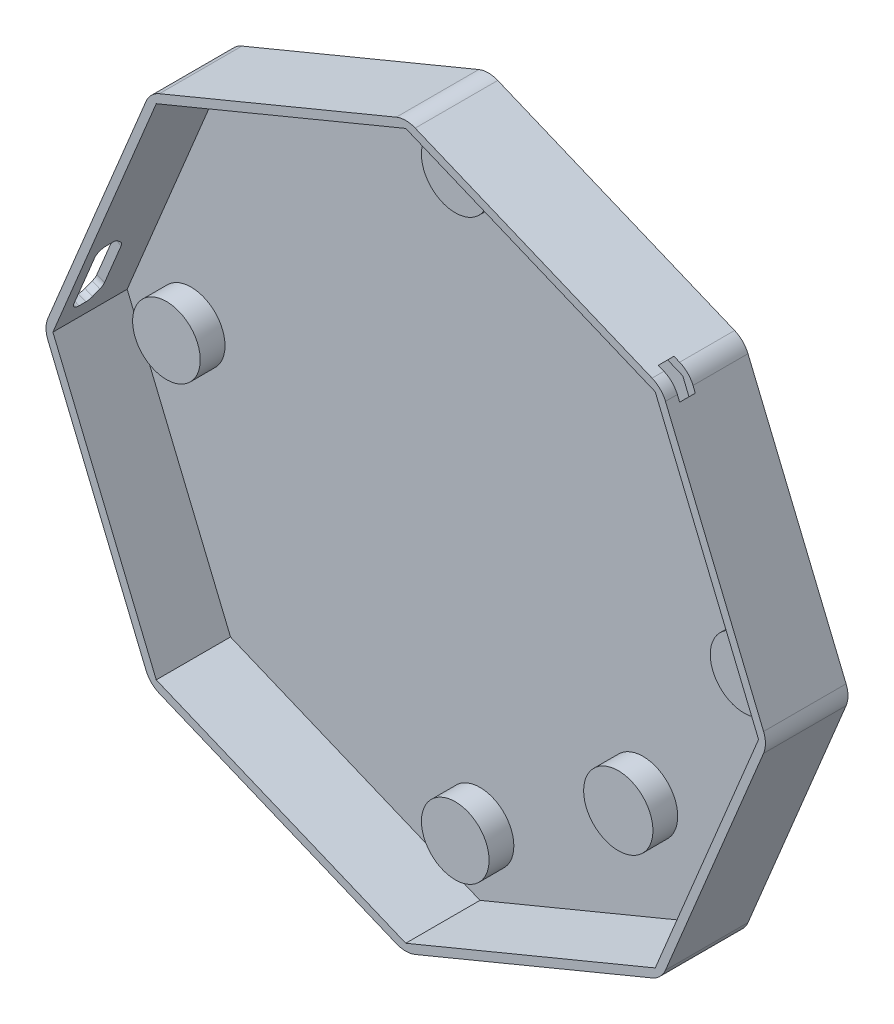
from build123d import *

# Parameters (mm, degrees)
BOSS_EXTRU_1_DEPTH           = 10
ESQUISSE2_R                  = 3.1
ENL_V_MAT_EXTRU_1_DEPTH      = 3
COQUE2_T                     = -1
CONG_1_R                     = 3
ENL_V_MAT_EXTRU_2_DEPTH      = 10
ESQUISSE4_R                  = 4.199805961
BOSS_EXTRU_2_DEPTH           = 3
ESQUISSE5_W                  = 3.651716426
ESQUISSE5_H                  = 1.9
ENL_V_MAT_EXTRU_3_DEPTH      = 11
ENL_V_MAT_EXTRU_3_DEPTH_BACK = 11
ENL_V_START                  = -0.3
ENL_V_MAT_EXTRU_4_DEPTH      = 4.2


with BuildPart() as part:
    # Esquisse1 → Boss.-Extru.1 (new body)
    with BuildSketch(Plane.XY):
        Polygon((0, -43.836884112), (30.997358022, -30.997358022), (43.836884112, 0), (30.997358022, 30.997358022), (0, 43.836884112), (-30.997358022, 30.997358022), (-43.836884112, 0), (-30.997358022, -30.997358022), align=None)
    extrude(amount=BOSS_EXTRU_1_DEPTH)

    # Esquisse2 → Enl_v. mat.-Extru.1 (cut)
    with BuildSketch(Plane(origin=(0, 0, 0), x_dir=(-1, 0, 0), z_dir=(0, 0, -1))):
        with Locations((0, 35)):
            Circle(ESQUISSE2_R)
        with Locations((35, 0)):
            Circle(ESQUISSE2_R)
        with Locations((0, -35)):
            Circle(ESQUISSE2_R)
        with Locations((-35, 0)):
            Circle(ESQUISSE2_R)
    extrude(amount=-ENL_V_MAT_EXTRU_1_DEPTH, mode=Mode.SUBTRACT)

    # Coque2
    coque2_openings = [part.faces().sort_by_distance(p)[0] for p in [
        (0, 0, 10),
    ]]
    offset(amount=COQUE2_T, openings=coque2_openings, kind=Kind.INTERSECTION)

    # Cong_1
    cong_1_edges = [part.edges().sort_by_distance(p)[0] for p in [
        (30.997358022, -30.997358022, 5),
        (0, -43.836884112, 5),
        (-30.997358022, -30.997358022, 5),
        (-43.836884112, 0, 5),
        (-30.997358022, 30.997358022, 5),
        (0, 43.836884112, 5),
        (30.997358022, 30.997358022, 5),
        (43.836884112, 0, 5),
    ]]
    fillet(cong_1_edges, radius=CONG_1_R)

    # Esquisse3 → Enl_v. mat.-Extru.2 (cut)
    with BuildSketch(Plane(origin=(-36.493241534, 15.115995578, 0), x_dir=(0, 0, -1), z_dir=(0.923879533, -0.382683432, 0))):
        with BuildLine():
            Line((-7.666279935, -14.17353482), (-6.84853173, -14.17353482))
            ThreePointArc((-6.84853173, -14.17353482), (-6.465848297, -14.097414353), (-6.141424949, -13.880641601))
            Line((-6.141424949, -13.880641601), (-5.504373219, -13.243589871))
            ThreePointArc((-5.504373219, -13.243589871), (-5.287600467, -12.919166523), (-5.21148, -12.53648309))
            Line((-5.21148, -12.53648309), (-5.21148, -7.262190369))
            ThreePointArc((-5.21148, -7.262190369), (-5.287600467, -6.879506937), (-5.504373219, -6.555083588))
            Line((-5.504373219, -6.555083588), (-6.141424949, -5.918031858))
            ThreePointArc((-6.141424949, -5.918031858), (-6.465848297, -5.701259107), (-6.84853173, -5.625138639))
            Line((-6.84853173, -5.625138639), (-7.666279935, -5.625138639))
            ThreePointArc((-7.666279935, -5.625138639), (-8.373386716, -5.918031858), (-8.666279935, -6.625138639))
            Line((-8.666279935, -6.625138639), (-8.666279935, -13.17353482))
            ThreePointArc((-8.666279935, -13.17353482), (-8.373386716, -13.880641601), (-7.666279935, -14.17353482))
        make_face()
    extrude(amount=-ENL_V_MAT_EXTRU_2_DEPTH, mode=Mode.SUBTRACT)

    # Esquisse4 → Boss.-Extru.2 (add)
    with BuildSketch(Plane.XY.offset(1)):
        with Locations((19.756285748, -21.963635985)):
            Circle(ESQUISSE4_R)
    extrude(amount=BOSS_EXTRU_2_DEPTH)

    # Esquisse5 → Enl_v. mat.-Extru.3 (cut, two sides)
    with BuildSketch(Plane(origin=(30.661101875, 30.661101875, 0), x_dir=(-0.707106781, 0.707106781, 0), z_dir=(-0.707106781, -0.707106781, 0))) as enl_v_mat_extru_3_sk:
        with Locations((0.007298531, -7.61148)):
            Rectangle(ESQUISSE5_W, ESQUISSE5_H)
    extrude(amount=ENL_V_MAT_EXTRU_3_DEPTH, mode=Mode.SUBTRACT)
    extrude(enl_v_mat_extru_3_sk.sketch, amount=-ENL_V_MAT_EXTRU_3_DEPTH_BACK, mode=Mode.SUBTRACT)

    # Esquisse6 → Enl_v. mat.-Extru.4 (cut)
    with BuildSketch(Plane.XY.offset(10).offset(ENL_V_START)):
        Polygon((26.258054531, 32.527484923), (32.482135733, 26.303403722), (28.600771667, 22.422039656), (22.376690466, 28.646120858), align=None)
    extrude(amount=-ENL_V_MAT_EXTRU_4_DEPTH, mode=Mode.SUBTRACT)


solid = part.part
